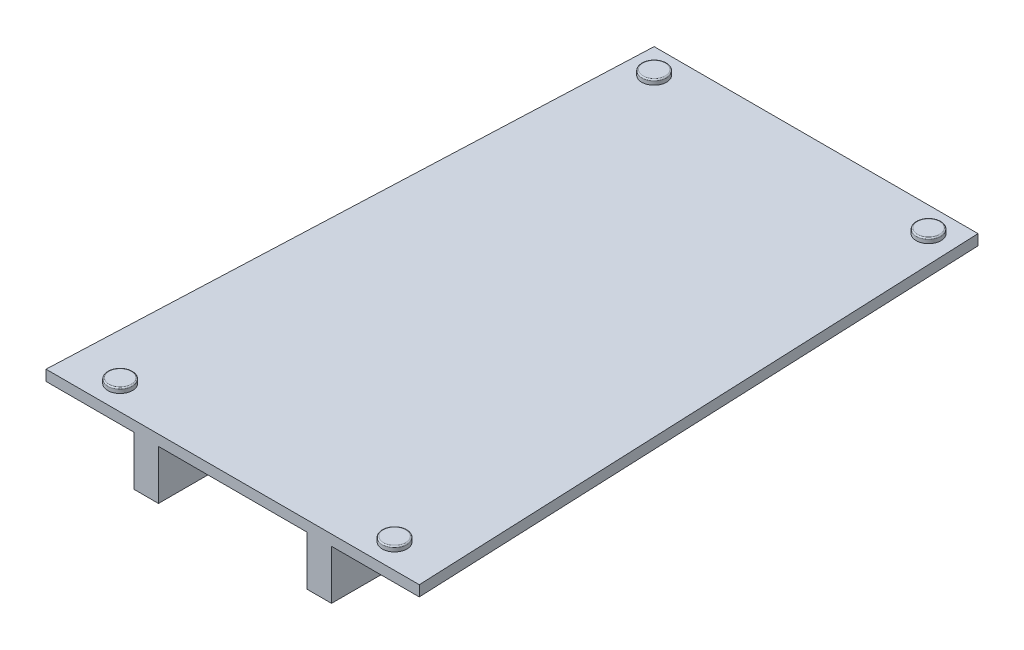
from build123d import *

# Parameters (mm, degrees)
BOSS_EXTRUDE1_DEPTH     = 4.3
SKETCH3_W               = 10
SKETCH3_H               = 236
BOSS_EXTRUDE2_DEPTH     = 20
SKETCH4_R               = 5
BOSS_EXTRUDE3_DEPTH     = 2
FILLET1_R               = 0.5
SKETCH5_R               = 2.5
CUT_EXTRUDE1_DEPTH      = 36.5
CUT_EXTRUDE1_DEPTH_BACK = 116.5


with BuildPart() as part:
    # Sketch2 → Boss-Extrude1 (new body)
    with BuildSketch(Plane(origin=(0, 0, 0), x_dir=(1, 0, 0), z_dir=(0, 1, 0))):
        Polygon((-75.5, -118), (0, -118), (0, 118), (-65.5, 118), align=None)
        Polygon((0, 118), (0, -118), (75.5, -118), (65.5, 118), align=None)
    extrude(amount=BOSS_EXTRUDE1_DEPTH)

    # Sketch3 → Boss-Extrude2 (add)
    with BuildSketch(Plane.XZ):
        with Locations((-35, 0)):
            Rectangle(SKETCH3_W, SKETCH3_H)
        with Locations((35, 0)):
            Rectangle(SKETCH3_W, SKETCH3_H)
    extrude(amount=BOSS_EXTRUDE2_DEPTH)

    # Sketch4 → Boss-Extrude3 (add)
    with BuildSketch(Plane(origin=(0, 4.3, 0), x_dir=(1, 0, 0), z_dir=(0, 1, 0))):
        with Locations((-55.5, 108)):
            Circle(SKETCH4_R)
        with Locations((55.5, 108)):
            Circle(SKETCH4_R)
        with Locations((-55.5, -108)):
            Circle(SKETCH4_R)
        with Locations((55.5, -108)):
            Circle(SKETCH4_R)
    extrude(amount=BOSS_EXTRUDE3_DEPTH)

    # Fillet1
    fillet1_edges = [part.edges().sort_by_distance(p)[0] for p in [
        (-60.5, 6.3, -108),
        (50.5, 6.3, -108),
        (-60.5, 6.3, 108),
        (50.5, 6.3, 108),
    ]]
    fillet(fillet1_edges, radius=FILLET1_R)

    # Sketch5 → Cut-Extrude1 (cut, two sides)
    with BuildSketch(Plane.ZY.offset(40)) as cut_extrude1_sk:
        with Locations((-59, -10)):
            Circle(SKETCH5_R)
        with Locations((59, -10)):
            Circle(SKETCH5_R)
    extrude(amount=CUT_EXTRUDE1_DEPTH, mode=Mode.SUBTRACT)
    extrude(cut_extrude1_sk.sketch, amount=-CUT_EXTRUDE1_DEPTH_BACK, mode=Mode.SUBTRACT)


solid = part.part
